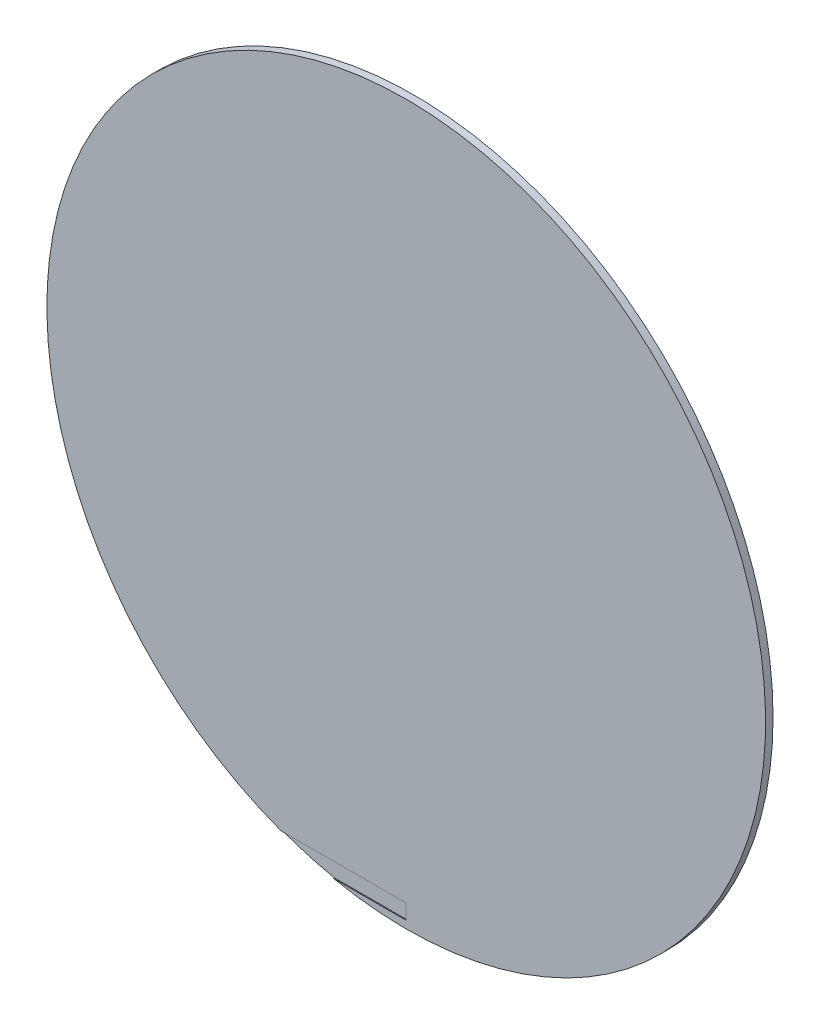
from build123d import *

# Parameters (mm, degrees)
SKETCH1_R           = 152.4
BOSS_EXTRUDE1_DEPTH = 3.175
CUT_EXTRUDE2_START  = -3.175
SKETCH2_W           = 117.669510625
SKETCH2_H           = 6.35
CUT_EXTRUDE2_DEPTH  = 0.396875


with BuildPart() as part:
    # Sketch1 → Boss-Extrude1 (new body)
    with BuildSketch(Plane.XY):
        Circle(SKETCH1_R)
    extrude(amount=BOSS_EXTRUDE1_DEPTH)

    # Sketch2 → Cut-Extrude2 (cut)
    with BuildSketch(Plane(origin=(0, 0, 0), x_dir=(-1, 0, 0), z_dir=(0, 0, -1)).offset(CUT_EXTRUDE2_START)):
        with Locations((58.834755313, -146.05)):
            Rectangle(SKETCH2_W, SKETCH2_H)
    extrude(amount=CUT_EXTRUDE2_DEPTH, mode=Mode.SUBTRACT)


solid = part.part
